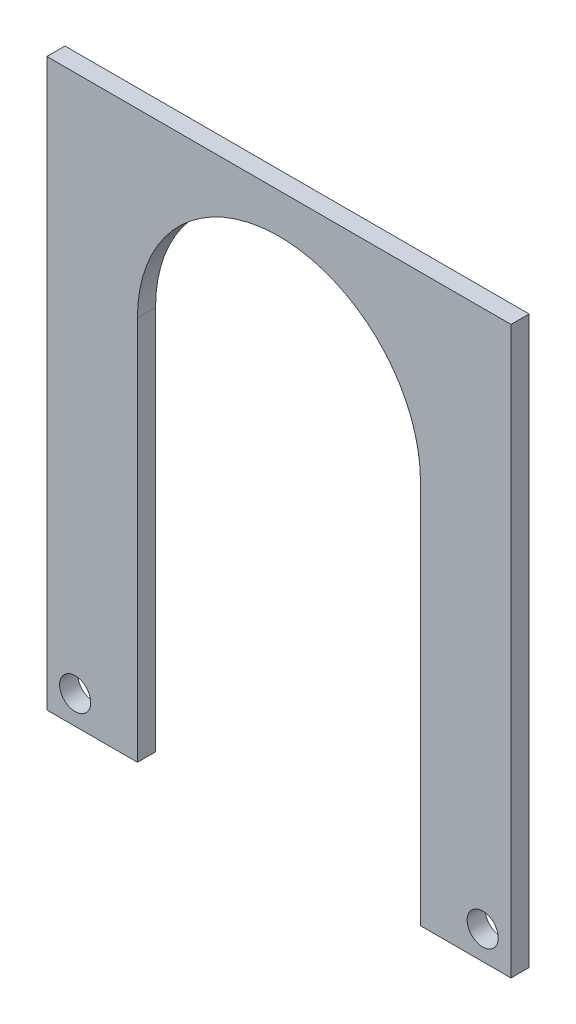
from build123d import *

# Parameters (mm, degrees)
SKETCH1_W           = 150
SKETCH1_H           = 160
BOSS_EXTRUDE1_DEPTH = 3.2
CUT_EXTRUDE1_REACH  = 5.2
CUT_EXTRUDE2_REACH  = 5.2
SKETCH3_R           = 2.75


with BuildPart() as part:
    # Sketch1 → Boss-Extrude1 (new body)
    with BuildSketch(Plane.XY):
        Rectangle(SKETCH1_W, SKETCH1_H)
    extrude(amount=BOSS_EXTRUDE1_DEPTH)

    # Sketch2 → Cut-Extrude1 (cut, up to next)
    with BuildSketch(Plane.XY.offset(3.2), mode=Mode.PRIVATE) as cut_extrude1_sk1:
        with BuildLine():
            Line((-25, -12), (-25, -80))
            Line((-25, -80), (25, -80))
            Line((25, -80), (25, -12))
            ThreePointArc((25, -12), (0, 13), (-25, -12))
        make_face()
    cut_extrude1_tool1 = extrude(cut_extrude1_sk1.sketch, amount=-CUT_EXTRUDE1_REACH, mode=Mode.PRIVATE) & part.part
    add(cut_extrude1_tool1.solids().sort_by_distance((0, -36.004881, 3.2))[0], mode=Mode.SUBTRACT)

    # Sketch3 → Cut-Extrude2 (cut, up to next)
    with BuildSketch(Plane.XY.offset(3.2), mode=Mode.PRIVATE) as cut_extrude2_sk1:
        with Locations((36, -75)):
            Circle(SKETCH3_R)
    cut_extrude2_tool1 = extrude(cut_extrude2_sk1.sketch, amount=-CUT_EXTRUDE2_REACH, mode=Mode.PRIVATE) & part.part
    add(cut_extrude2_tool1.solids().sort_by_distance((36, -75, 3.2))[0], mode=Mode.SUBTRACT)
    # Sketch3 → Cut-Extrude2 (cut, up to next)
    with BuildSketch(Plane.XY.offset(3.2), mode=Mode.PRIVATE) as cut_extrude2_sk2:
        with Locations((-36, -75)):
            Circle(SKETCH3_R)
    cut_extrude2_tool2 = extrude(cut_extrude2_sk2.sketch, amount=-CUT_EXTRUDE2_REACH, mode=Mode.PRIVATE) & part.part
    add(cut_extrude2_tool2.solids().sort_by_distance((-36, -75, 3.2))[0], mode=Mode.SUBTRACT)
    # Sketch3 → Cut-Extrude2 (cut, up to next)
    with BuildSketch(Plane.XY.offset(3.2), mode=Mode.PRIVATE) as cut_extrude2_sk3:
        Polygon((-41, 20), (-41, -80), (-75, -80), (-75, 80), (75, 80), (75, -80), (41, -80), (41, 20), align=None)
    cut_extrude2_tool3 = extrude(cut_extrude2_sk3.sketch, amount=-CUT_EXTRUDE2_REACH, mode=Mode.PRIVATE) & part.part
    add(cut_extrude2_tool3.solids().sort_by_distance((-43.193171, -30, 3.2))[0], mode=Mode.SUBTRACT)


solid = part.part
